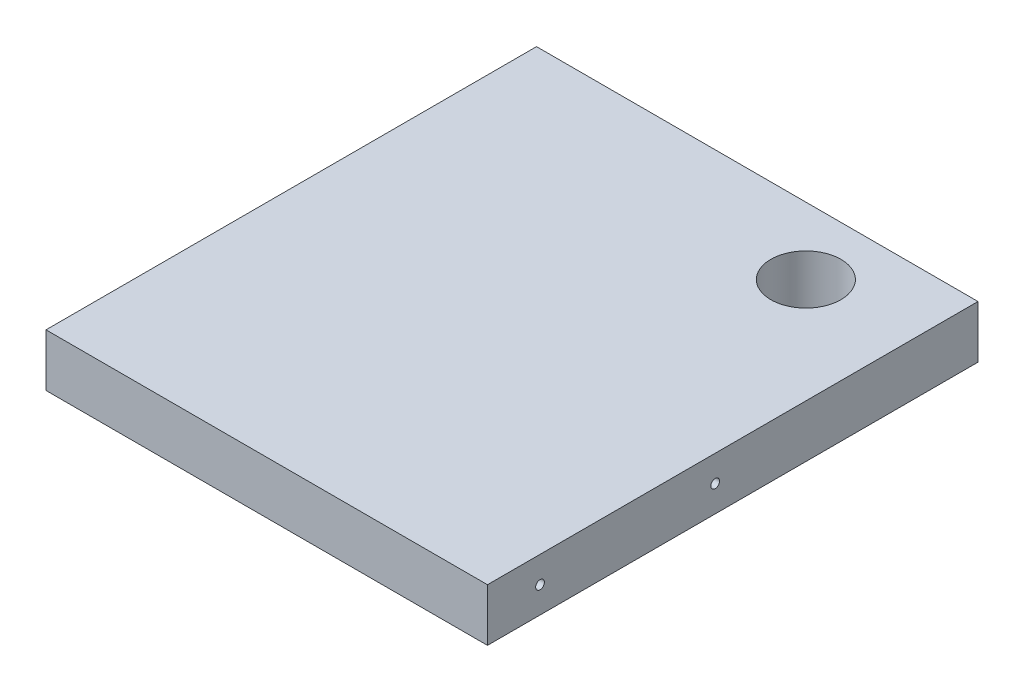
from build123d import *

# Parameters (mm, degrees)
SKETCH1_W                  = 160.02
SKETCH1_H                  = 19.05
BOSS_EXTRUDE1_DEPTH        = 177.8
HOLE1_D                    = 1.98374
HOLE1_DEPTH                = 31.75
HOLE1_CSINK_D              = 10.16
HOLE1_CSINK_ANGLE          = 82
HOLE1_TIP                  = 0.595975622
HOLE3_D                    = 3.175
HOLE3_DEPTH                = 31.75
HOLE3_CSINK_D              = 10.16
HOLE3_CSINK_ANGLE          = 82
HOLE3_TIP                  = 0.953866233
HOLE4_D                    = 3.175
HOLE4_DEPTH                = 31.75
HOLE4_CSINK_D              = 10.16
HOLE4_CSINK_ANGLE          = 82
HOLE4_TIP                  = 0.953866233
F_1_1_DIAMETER_HOLE1_D     = 25.4
F_1_1_DIAMETER_HOLE1_DEPTH = 19.05


with BuildPart() as part:
    # Sketch1 → Boss-Extrude1 (new body)
    with BuildSketch(Plane.XY):
        with Locations((0, 5836.579380546)):
            Rectangle(SKETCH1_W, SKETCH1_H)
    extrude(amount=BOSS_EXTRUDE1_DEPTH)

    # Hole1
    with Locations(Plane(origin=(0, 0, -19.05), x_dir=(-1, 0, 0), z_dir=(0, 0, -1))):
        with Locations((0.162188158, 5756.275), (0, 5926.455000144), (-203.2, 5926.455000144), (-406.4, 5926.455000144), (-406.562188158, 5756.275), (-203.362188158, 5756.275), (-359.617959774, 5737.225), (-428.613879322, 5737.225), (-421.257783583, 5578.475), (-319.657783583, 5578.475), (-116.457783583, 5578.475), (-424.072610901, 5559.425), (-358.104203634, 5559.425), (-418.230271303, 5400.675), (-316.630271303, 5400.675), (-113.430271303, 5400.675), (-419.531342481, 5381.625), (-356.590447494, 5381.625), (-415.202759023, 5222.875), (-313.602759023, 5222.875), (-110.402759023, 5222.875), (-414.990074061, 5203.825), (-355.076691354, 5203.825), (355.076691354, 5203.825), (414.990074061, 5203.825), (110.402759023, 5222.875), (313.602759023, 5222.875), (415.202759023, 5222.875), (356.590447494, 5381.625), (419.531342481, 5381.625), (113.430271303, 5400.675), (316.630271303, 5400.675), (418.230271303, 5400.675), (358.104203634, 5559.425), (424.072610901, 5559.425), (116.457783583, 5578.475), (319.657783583, 5578.475), (421.257783583, 5578.475), (428.613879322, 5737.225), (359.617959774, 5737.225), (203.362188158, 5756.275), (406.562188158, 5756.275), (406.4, 5926.455000144), (203.2, 5926.455000144), (-0.162188158, 5756.275), (0, 5836.579380546), (-60.96, 5836.579380546), (60.96, 5836.579380546)):
            CounterSinkHole(HOLE1_D / 2, HOLE1_CSINK_D / 2, depth=HOLE1_DEPTH, counter_sink_angle=HOLE1_CSINK_ANGLE)
            with Locations((0, 0, -(HOLE1_DEPTH + HOLE1_TIP / 2))):  # 118° drill point
                Cone(0, HOLE1_D / 2, HOLE1_TIP, mode=Mode.SUBTRACT)

    # Hole3
    with Locations(Plane(origin=(99.06, 0, -2683.51), x_dir=(0, 0, -1), z_dir=(1, 0, 0))):
        with Locations((-2778.76, 5836.579380546), (-2842.26, 5836.579380546)):
            CounterSinkHole(HOLE3_D / 2, HOLE3_CSINK_D / 2, depth=HOLE3_DEPTH, counter_sink_angle=HOLE3_CSINK_ANGLE)
            with Locations((0, 0, -(HOLE3_DEPTH + HOLE3_TIP / 2))):  # 118° drill point
                Cone(0, HOLE3_D / 2, HOLE3_TIP, mode=Mode.SUBTRACT)

    # Hole4
    with Locations(Plane(origin=(-99.06, 0, -2683.51), x_dir=(0, 0, 1), z_dir=(-1, 0, 0))):
        with Locations((2778.76, 5836.579380546), (2842.26, 5836.579380546)):
            CounterSinkHole(HOLE4_D / 2, HOLE4_CSINK_D / 2, depth=HOLE4_DEPTH, counter_sink_angle=HOLE4_CSINK_ANGLE)
            with Locations((0, 0, -(HOLE4_DEPTH + HOLE4_TIP / 2))):  # 118° drill point
                Cone(0, HOLE4_D / 2, HOLE4_TIP, mode=Mode.SUBTRACT)

    # 1 (1) Diameter Hole1
    with Locations(Plane(origin=(0, 5827.054380546, 0), x_dir=(-1, 0, 0), z_dir=(0, -1, 0))):
        with Locations((-41.91, -24.295160427)):
            Hole(F_1_1_DIAMETER_HOLE1_D / 2, depth=F_1_1_DIAMETER_HOLE1_DEPTH)


solid = part.part
